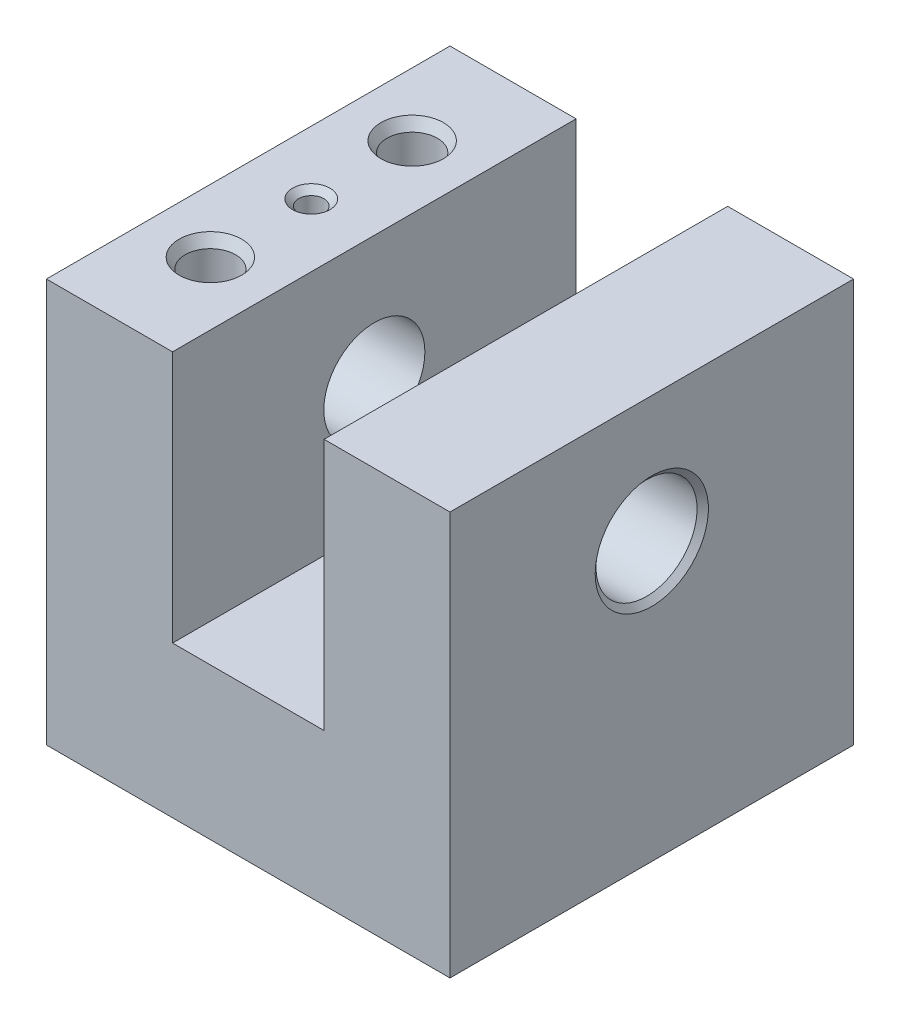
from build123d import *

# Parameters (mm, degrees)
EXTRUDE1_DEPTH                    = 50.8
SKETCH3_R                         = 1.5875
CUT_EXTRUDE2_DEPTH                = 7.62
CHAMFER3_SIZE                     = 0.762
CHAMFER3_SIZE2                    = 1.268180966
CHAMFER4_SIZE                     = 0.762
SKETCH4_R                         = 6.3627
CUT_EXTRUDE3_DEPTH                = 51.8
F_1_4_20_TAPPED_HOLE1_D           = 5.1054
F_1_4_20_TAPPED_HOLE1_DEPTH       = 16.51
F_1_4_20_TAPPED_HOLE1_CBORE_D     = 6.35
F_1_4_20_TAPPED_HOLE1_CBORE_DEPTH = 12.7
F_1_4_20_TAPPED_HOLE1_TIP         = 1.533816902
CHAMFER6_SIZE                     = 0.762
CHAMFER6_SIZE2                    = 1.319822715
CHAMFER7_SIZE                     = 0.762
CHAMFER7_SIZE2                    = 0.662396494
CHAMFER7_PART_2_SIZE              = 0.762
CHAMFER7_PART_2_SIZE2             = 0.662396494


with BuildPart() as part:
    # Sketch1 → Extrude1 (new body)
    with BuildSketch(Plane.XY):
        Polygon((0, 0), (50.8, 0), (50.8, 50.8), (34.9504, 50.8), (34.9504, 19.05), (15.875, 19.05), (15.875, 50.8), (0, 50.8), align=None)
    extrude(amount=EXTRUDE1_DEPTH)

    # Sketch3 → Cut-Extrude2 (cut)
    with BuildSketch(Plane(origin=(0, 50.8, 0), x_dir=(-1, 0, 0), z_dir=(0, 1, 0))):
        with Locations(Location((-7.9375, 25.4, 0), (0, 0, 90))):  # turned: the seam where the file's is
            Circle(SKETCH3_R)
    extrude(amount=-CUT_EXTRUDE2_DEPTH, mode=Mode.SUBTRACT)

    # Chamfer3
    chamfer3_edges = [part.edges().sort_by_distance(p)[0] for p in [
        (7.9375, 43.18, 23.8125),
    ]]
    chamfer3_side = [part.faces().sort_by_distance(p)[0] for p in [
        (7.9375, 46.99, 23.8125),
    ]]
    chamfer(chamfer3_edges, length=CHAMFER3_SIZE, length2=CHAMFER3_SIZE2, reference=chamfer3_side[0])

    # Chamfer4
    chamfer4_edges = [part.edges().sort_by_distance(p)[0] for p in [
        (7.9375, 50.8, 23.8125),
    ]]
    chamfer(chamfer4_edges, length=CHAMFER4_SIZE)

    # Sketch4 → Cut-Extrude3 (cut, through all)
    with BuildSketch(Plane(origin=(50.8, 0, 0), x_dir=(0, 0, -1), z_dir=(1, 0, 0))):
        with Locations(Location((-25.4, 34.925, 0), (0, 0, 90))):  # turned: the seam where the file's is
            Circle(SKETCH4_R)
    extrude(amount=-CUT_EXTRUDE3_DEPTH, mode=Mode.SUBTRACT)

    # 1/4-20 Tapped Hole1
    with Locations(Plane(origin=(7.9375, 50.8, 12.7), x_dir=(0, 0, 1), z_dir=(0, 1, 0))):
        with Locations((0, 0), (25.4, 0)):
            CounterBoreHole(F_1_4_20_TAPPED_HOLE1_D / 2, F_1_4_20_TAPPED_HOLE1_CBORE_D / 2, F_1_4_20_TAPPED_HOLE1_CBORE_DEPTH, depth=F_1_4_20_TAPPED_HOLE1_DEPTH)
            with Locations((0, 0, -(F_1_4_20_TAPPED_HOLE1_DEPTH + F_1_4_20_TAPPED_HOLE1_TIP / 2))):  # 118° drill point
                Cone(0, F_1_4_20_TAPPED_HOLE1_D / 2, F_1_4_20_TAPPED_HOLE1_TIP, mode=Mode.SUBTRACT)

    # Chamfer6
    chamfer6_edges = [part.edges().sort_by_distance(p)[0] for p in [
        (7.9375, 50.8, 34.925),
        (7.9375, 50.8, 9.525),
    ]]
    chamfer6_side = [part.faces().sort_by_distance(p)[0] for p in [
        (15.342773016, 50.8, 25.4),
    ]]
    chamfer(chamfer6_edges, length=CHAMFER6_SIZE, length2=CHAMFER6_SIZE2, reference=chamfer6_side[0])

    # Chamfer7
    chamfer7_edges = [part.edges().sort_by_distance(p)[0] for p in [
        (0, 28.5623, 25.4),
    ]]
    chamfer7_side = [part.faces().sort_by_distance(p)[0] for p in [
        (7.9375, 28.5623, 25.4),
    ]]
    chamfer(chamfer7_edges, length=CHAMFER7_SIZE, length2=CHAMFER7_SIZE2, reference=chamfer7_side[0])

    # Chamfer7 part 2
    chamfer7_part_2_edges = [part.edges().sort_by_distance(p)[0] for p in [
        (50.8, 28.5623, 25.4),
    ]]
    chamfer7_part_2_side = [part.faces().sort_by_distance(p)[0] for p in [
        (50.8, 24.906235921, 25.4),
    ]]
    chamfer(chamfer7_part_2_edges, length=CHAMFER7_PART_2_SIZE, length2=CHAMFER7_PART_2_SIZE2, reference=chamfer7_part_2_side[0])


solid = part.part
